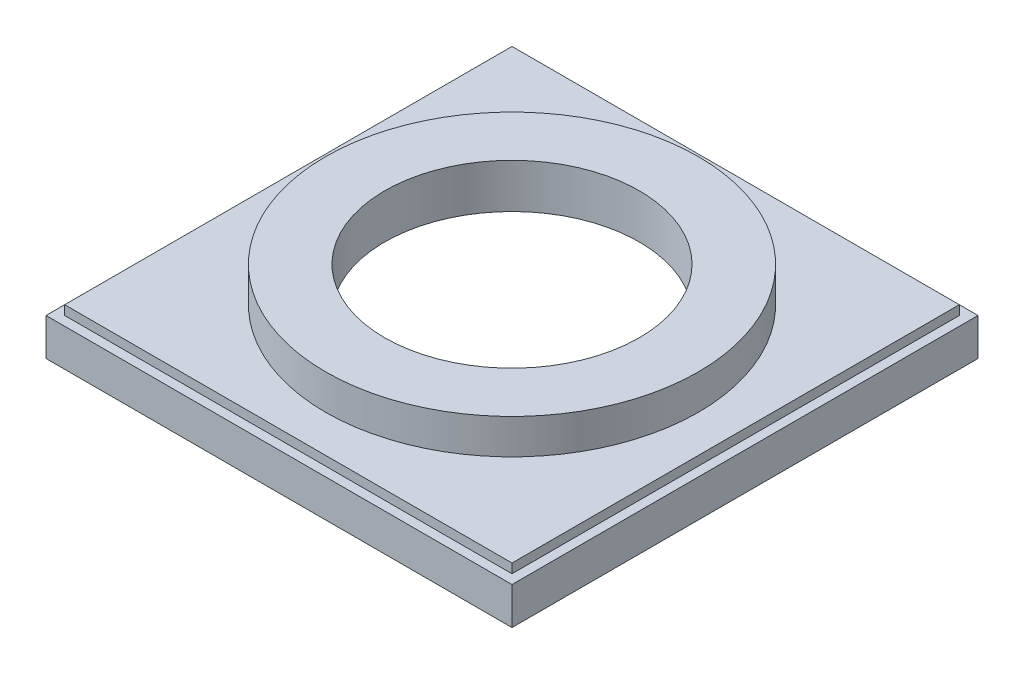
from build123d import *

# Parameters (mm, degrees)
SKETCH1_W           = 317.5
SKETCH1_H           = 317.5
SKETCH1_W_2         = 266.7
SKETCH1_H_2         = 266.7
BOSS_EXTRUDE1_DEPTH = 25.4
SKETCH2_W           = 304.8
SKETCH2_H           = 304.8
BOSS_EXTRUDE2_DEPTH = 6.35
SKETCH3_R           = 127
BOSS_EXTRUDE3_DEPTH = 23.876
SKETCH4_R           = 86.741
CUT_EXTRUDE1_DEPTH  = 56.626


with BuildPart() as part:
    # Sketch1 → Boss-Extrude1 (new body)
    with BuildSketch(Plane(origin=(0, 0, 0), x_dir=(1, 0, 0), z_dir=(0, 1, 0))):
        Rectangle(SKETCH1_W, SKETCH1_H)
        Rectangle(SKETCH1_W_2, SKETCH1_H_2, mode=Mode.SUBTRACT)
    extrude(amount=BOSS_EXTRUDE1_DEPTH)

    # Sketch2 → Boss-Extrude2 (add)
    with BuildSketch(Plane(origin=(0, 25.4, 0), x_dir=(1, 0, 0), z_dir=(0, 1, 0))):
        Rectangle(SKETCH2_W, SKETCH2_H)
    extrude(amount=BOSS_EXTRUDE2_DEPTH)

    # Sketch3 → Boss-Extrude3 (add)
    with BuildSketch(Plane(origin=(0, 31.75, 0), x_dir=(1, 0, 0), z_dir=(0, 1, 0))):
        Circle(SKETCH3_R)
    extrude(amount=BOSS_EXTRUDE3_DEPTH)

    # Sketch4 → Cut-Extrude1 (cut, through all)
    with BuildSketch(Plane(origin=(0, 55.626, 0), x_dir=(1, 0, 0), z_dir=(0, 1, 0))):
        Circle(SKETCH4_R)
    extrude(amount=-CUT_EXTRUDE1_DEPTH, mode=Mode.SUBTRACT)


solid = part.part
